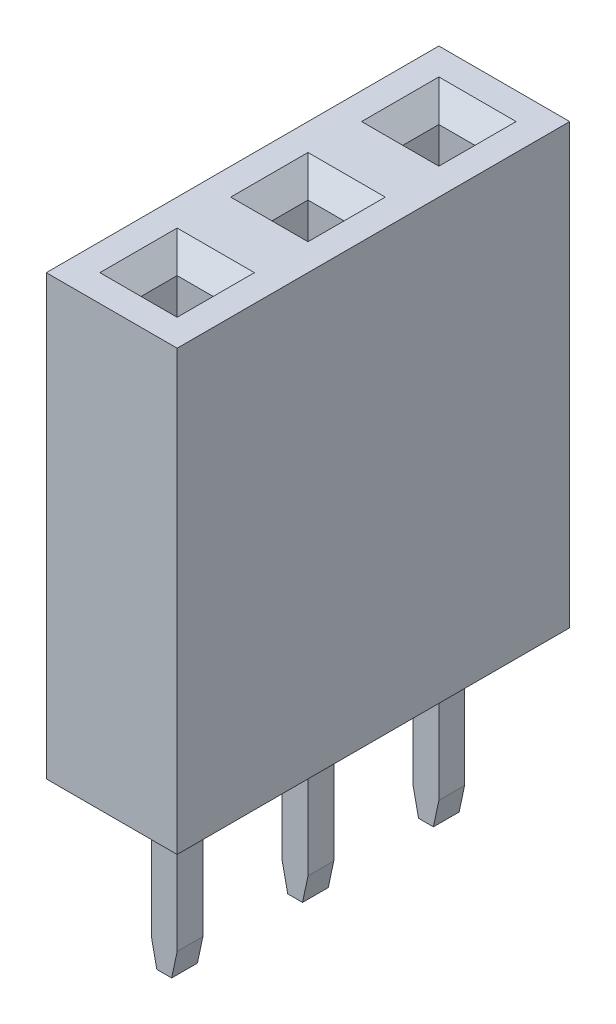
from build123d import *
from OCP.BRepFilletAPI import BRepFilletAPI_MakeChamfer

# Parameters (mm, degrees)
SKETCH_1_W                          = 2.54
SKETCH_1_H                          = 2.54
EXTRUDE_1_DEPTH                     = 8.51
SKETCH_4_W                          = 0.7
SKETCH_4_H                          = 0.7
CUT_EXTRUDE_1_DEPTH                 = 8.21
CHAMFER_3_SIZE                      = 0.4
SKETCH_2_W                          = 0.5
SKETCH_2_H                          = 0.5
EXTRUDE_2_DEPTH                     = 3.15
CHAMFER_2_SIZE                      = 0.5
CHAMFER_2_SIZE2                     = 0.106278281
PATTERN_LINEAR_1_COUNT              = 3
PATTERN_LINEAR_1_PITCH              = 2.54
CHAMFER_3_OF_PATTERN_LINEAR_1_SIZE  = 0.4
CHAMFER_2_OF_PATTERN_LINEAR_1_SIZE  = 0.5
CHAMFER_2_OF_PATTERN_LINEAR_1_SIZE2 = 0.106278281


with BuildPart() as part:
    # Эскиз1 → Бобышка-Вытянуть1 (new body)
    with BuildSketch(Plane(origin=(0, 0, 0), x_dir=(-1, 0, 0), z_dir=(0, 1, 0))):
        Rectangle(SKETCH_1_W, SKETCH_1_H)
    extrude_1 = extrude(amount=EXTRUDE_1_DEPTH)

    # Эскиз4 → Вырез-Вытянуть1 (cut)
    with BuildSketch(Plane(origin=(0, 8.51, 0), x_dir=(1, 0, 0), z_dir=(0, 1, 0))):
        Rectangle(SKETCH_4_W, SKETCH_4_H)
    cut_extrude_1 = extrude(amount=-CUT_EXTRUDE_1_DEPTH, mode=Mode.SUBTRACT)

    # Фаска3
    chamfer_3_edges = [part.edges().sort_by_distance(p)[0] for p in [
        (-0.35, 8.51, 0),
        (0, 8.51, 0.35),
        (0.35, 8.51, 0),
        (0, 8.51, -0.35),
    ]]
    chamfer(chamfer_3_edges, length=CHAMFER_3_SIZE)

    # Эскиз2 → Бобышка-Вытянуть2 (add)
    with BuildSketch(Plane(origin=(0, 0, 0), x_dir=(-1, 0, 0), z_dir=(0, 1, 0))):
        Rectangle(SKETCH_2_W, SKETCH_2_H)
    extrude_2 = extrude(amount=-EXTRUDE_2_DEPTH)

    # Фаска2: one chamfer whose edges measure the first distance from different faces: ONE call of the kernel's chamfer builder (chamfer() names one face for all edges)
    chamfer_2_edges_1 = [part.edges().sort_by_distance(p)[0] for p in [
        (-0.25, -3.15, 0),
    ]]
    chamfer_2_side_1 = [part.faces().sort_by_distance(p)[0] for p in [
        (-0.25, -1.575, 0),
    ]]
    chamfer_2_edges_2 = [part.edges().sort_by_distance(p)[0] for p in [
        (0.25, -3.15, 0),
    ]]
    chamfer_2_side_2 = [part.faces().sort_by_distance(p)[0] for p in [
        (0.25, -1.575, 0),
    ]]
    chamfer_2 = BRepFilletAPI_MakeChamfer(part.part.solid().wrapped)
    for e in chamfer_2_edges_1:
        chamfer_2.Add(CHAMFER_2_SIZE, CHAMFER_2_SIZE2, e.wrapped, chamfer_2_side_1[0].wrapped)  # the first distance lies on this face
    for e in chamfer_2_edges_2:
        chamfer_2.Add(CHAMFER_2_SIZE, CHAMFER_2_SIZE2, e.wrapped, chamfer_2_side_2[0].wrapped)  # the first distance lies on this face
    add(Compound.cast(chamfer_2.Shape()), mode=Mode.REPLACE)

    # Линейный массив1: Бобышка-Вытянуть1, Вырез-Вытянуть1, Бобышка-Вытянуть2 ×3
    with Locations(*[(0, 0, -i * PATTERN_LINEAR_1_PITCH) for i in range(1, PATTERN_LINEAR_1_COUNT)]):
        add(extrude_1)
        add(cut_extrude_1, mode=Mode.SUBTRACT)
        add(extrude_2)

    # Фаска3 of Линейный массив1
    chamfer_3_of_pattern_linear_1_edges = [part.edges().sort_by_distance(p)[0] for p in [
        (-0.35, 8.51, -2.54),
        (0, 8.51, -2.19),
        (0.35, 8.51, -2.54),
        (0, 8.51, -2.89),
        (-0.35, 8.51, -5.08),
        (0, 8.51, -4.73),
        (0.35, 8.51, -5.08),
        (0, 8.51, -5.43),
    ]]
    chamfer(chamfer_3_of_pattern_linear_1_edges, length=CHAMFER_3_OF_PATTERN_LINEAR_1_SIZE)

    # Фаска2 of Линейный массив1: one chamfer whose edges measure the first distance from different faces: ONE call of the kernel's chamfer builder (chamfer() names one face for all edges)
    chamfer_2_of_pattern_linear_1_edges_1 = [part.edges().sort_by_distance(p)[0] for p in [
        (-0.25, -3.15, -2.54),
    ]]
    chamfer_2_of_pattern_linear_1_side_1 = [part.faces().sort_by_distance(p)[0] for p in [
        (-0.25, -1.575, -2.54),
    ]]
    chamfer_2_of_pattern_linear_1_edges_2 = [part.edges().sort_by_distance(p)[0] for p in [
        (0.25, -3.15, -2.54),
    ]]
    chamfer_2_of_pattern_linear_1_side_2 = [part.faces().sort_by_distance(p)[0] for p in [
        (0.25, -1.575, -2.54),
    ]]
    chamfer_2_of_pattern_linear_1_edges_3 = [part.edges().sort_by_distance(p)[0] for p in [
        (-0.25, -3.15, -5.08),
    ]]
    chamfer_2_of_pattern_linear_1_side_3 = [part.faces().sort_by_distance(p)[0] for p in [
        (-0.25, -1.575, -5.08),
    ]]
    chamfer_2_of_pattern_linear_1_edges_4 = [part.edges().sort_by_distance(p)[0] for p in [
        (0.25, -3.15, -5.08),
    ]]
    chamfer_2_of_pattern_linear_1_side_4 = [part.faces().sort_by_distance(p)[0] for p in [
        (0.25, -1.575, -5.08),
    ]]
    chamfer_2_of_pattern_linear_1 = BRepFilletAPI_MakeChamfer(part.part.solid().wrapped)
    for e in chamfer_2_of_pattern_linear_1_edges_1:
        chamfer_2_of_pattern_linear_1.Add(CHAMFER_2_OF_PATTERN_LINEAR_1_SIZE, CHAMFER_2_OF_PATTERN_LINEAR_1_SIZE2, e.wrapped, chamfer_2_of_pattern_linear_1_side_1[0].wrapped)  # the first distance lies on this face
    for e in chamfer_2_of_pattern_linear_1_edges_2:
        chamfer_2_of_pattern_linear_1.Add(CHAMFER_2_OF_PATTERN_LINEAR_1_SIZE, CHAMFER_2_OF_PATTERN_LINEAR_1_SIZE2, e.wrapped, chamfer_2_of_pattern_linear_1_side_2[0].wrapped)  # the first distance lies on this face
    for e in chamfer_2_of_pattern_linear_1_edges_3:
        chamfer_2_of_pattern_linear_1.Add(CHAMFER_2_OF_PATTERN_LINEAR_1_SIZE, CHAMFER_2_OF_PATTERN_LINEAR_1_SIZE2, e.wrapped, chamfer_2_of_pattern_linear_1_side_3[0].wrapped)  # the first distance lies on this face
    for e in chamfer_2_of_pattern_linear_1_edges_4:
        chamfer_2_of_pattern_linear_1.Add(CHAMFER_2_OF_PATTERN_LINEAR_1_SIZE, CHAMFER_2_OF_PATTERN_LINEAR_1_SIZE2, e.wrapped, chamfer_2_of_pattern_linear_1_side_4[0].wrapped)  # the first distance lies on this face
    add(Compound.cast(chamfer_2_of_pattern_linear_1.Shape()), mode=Mode.REPLACE)


solid = part.part
